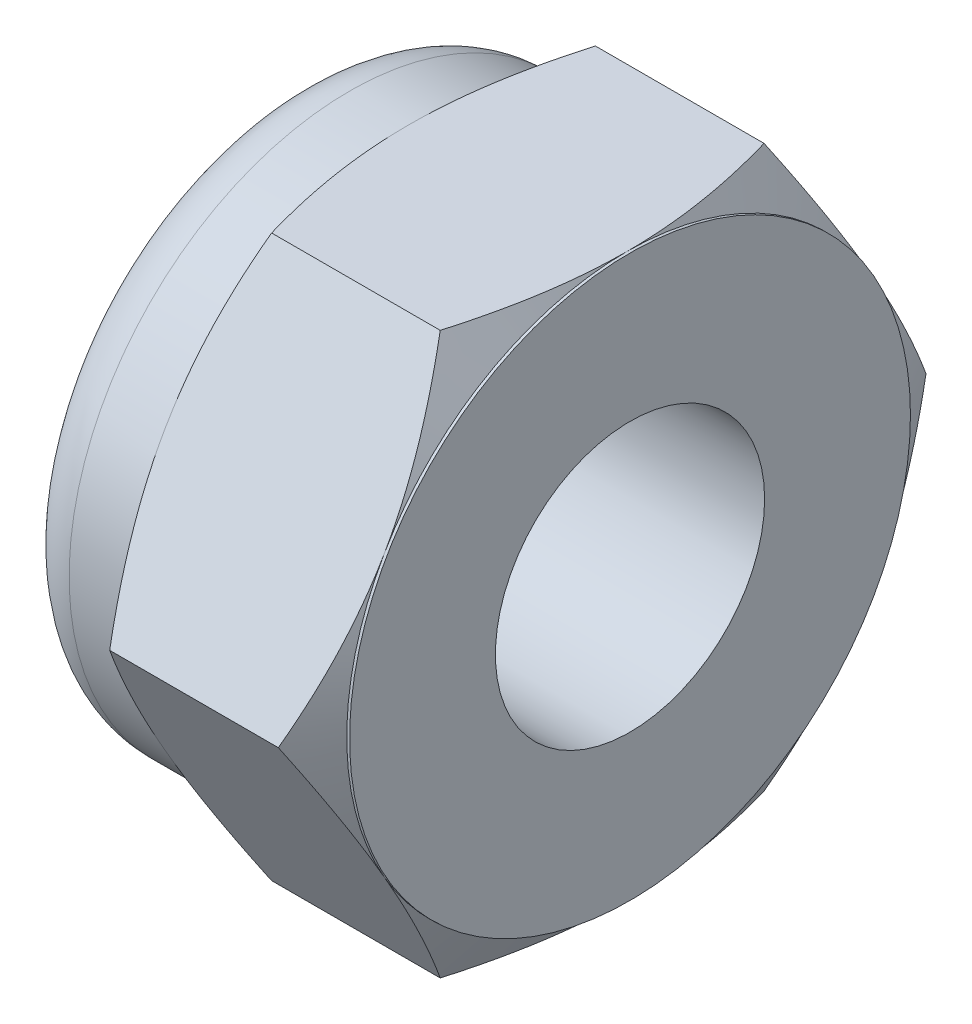
from build123d import *

# Parameters (mm, degrees)
SKIZZE6_R               = 5
GRUNDK_RPER_DEPTH       = 4
SKIZZE14_R              = 8.377499075
SCHNITT_SECHSKANT_DEPTH = 5
SKIZZE13_R              = 2.4
GEWINDE_DEPTH           = 5
SKIZZE19_W              = 1
SKIZZE19_H              = 1.6


with BuildPart() as part:
    # Skizze6 → Grundkörper (new body)
    with BuildSketch(Plane(origin=(0, 0, 0), x_dir=(0, 0, -1), z_dir=(1, 0, 0))):
        Circle(SKIZZE6_R)
    extrude(amount=-GRUNDK_RPER_DEPTH)

    # Skizze17 → Rotation2 (revolve)
    with BuildSketch(Plane.XY, mode=Mode.PRIVATE) as rotation2_sk:
        Polygon((-0.05, 5), (-2, 8.377499075), (-3.95, 5), align=None)
    revolve(rotation2_sk.sketch.rotate(Axis((0, 0, 0), (-1, 0, 0)), 90), axis=Axis((0, 0, 0), (-1, 0, 0)))  # turned: the seam where the file's is

    # Skizze14 → Schnitt Sechskant (cut, through all)
    with BuildSketch(Plane(origin=(0, 0, 0), x_dir=(0, 0, -1), z_dir=(1, 0, 0))):
        Circle(SKIZZE14_R)
        Polygon((2.886751346, -5), (5.773502692, 0), (2.886751346, 5), (-2.886751346, 5), (-5.773502692, 0), (-2.886751346, -5), align=None, mode=Mode.SUBTRACT)
    extrude(amount=-SCHNITT_SECHSKANT_DEPTH, mode=Mode.SUBTRACT)

    # Skizze13 → Gewinde (cut, through all)
    with BuildSketch(Plane(origin=(0, 0, 0), x_dir=(0, 0, -1), z_dir=(1, 0, 0))):
        Circle(SKIZZE13_R)
    extrude(amount=-GEWINDE_DEPTH, mode=Mode.SUBTRACT)

    # Skizze18 → Sicherungsmutter Rotation3 (revolve)
    with BuildSketch(Plane.XY, mode=Mode.PRIVATE) as sicherungsmutter_rotation3_sk:
        with BuildLine():
            Line((-4, 5), (-5, 5))
            ThreePointArc((-5, 5), (-5.707106781, 4.707106781), (-6, 4))
            Line((-6, 4), (-6, 3))
            Line((-6, 3), (-5, 3))
            Line((-5, 3), (-5, 4))
            Line((-5, 4), (-4, 4))
            Line((-4, 4), (-4, 5))
        make_face()
    revolve(sicherungsmutter_rotation3_sk.sketch.rotate(Axis((0, 0, 0), (-1, 0, 0)), 90), axis=Axis((0, 0, 0), (-1, 0, 0)))  # turned: the seam where the file's is


with BuildPart() as body_2:
    # Skizze19 → Sicherungsmutter Rotation4 (revolve)
    with BuildSketch(Plane.XY, mode=Mode.PRIVATE) as sicherungsmutter_rotation4_sk:
        with Locations((-4.5, 3.2)):
            Rectangle(SKIZZE19_W, SKIZZE19_H)
    revolve(sicherungsmutter_rotation4_sk.sketch.rotate(Axis((0, 0, 0), (-1, 0, 0)), 90), axis=Axis((0, 0, 0), (-1, 0, 0)))  # turned: the seam where the file's is


solid = Compound([part.part, body_2.part])
